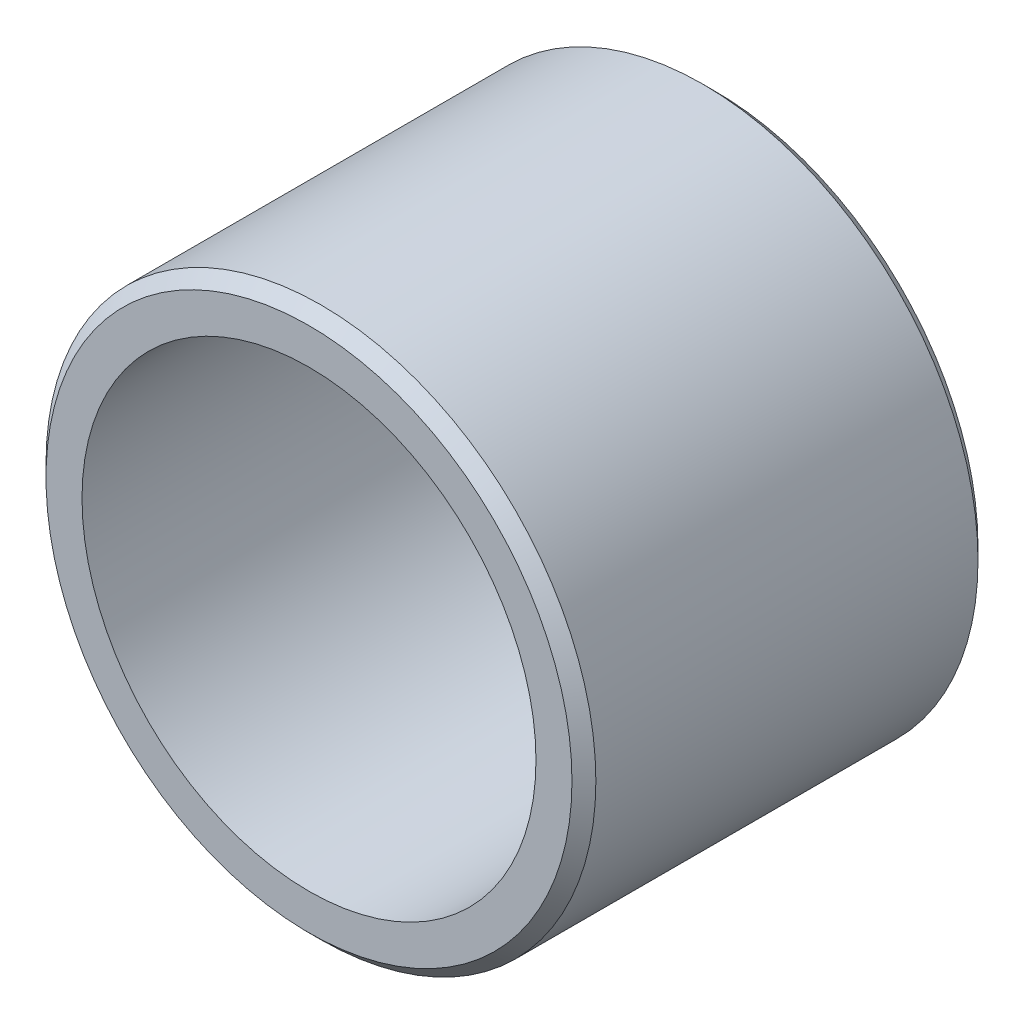
from build123d import *

# Parameters (mm, degrees)
SKETCH1_R           = 11.5062
SKETCH1_R_2         = 9.4996
BOSS_EXTRUDE1_DEPTH = 16.9926
CHAMFER1_SIZE       = 0.5


with BuildPart() as part:
    # Sketch1 → Boss-Extrude1 (new body)
    with BuildSketch(Plane.XY):
        Circle(SKETCH1_R)
        Circle(SKETCH1_R_2, mode=Mode.SUBTRACT)
    extrude(amount=-BOSS_EXTRUDE1_DEPTH)

    # Chamfer1
    chamfer1_edges = [part.edges().sort_by_distance(p)[0] for p in [
        (-11.5062, 0, 0),
        (-11.5062, 0, -16.9926),
    ]]
    chamfer(chamfer1_edges, length=CHAMFER1_SIZE)


solid = part.part
